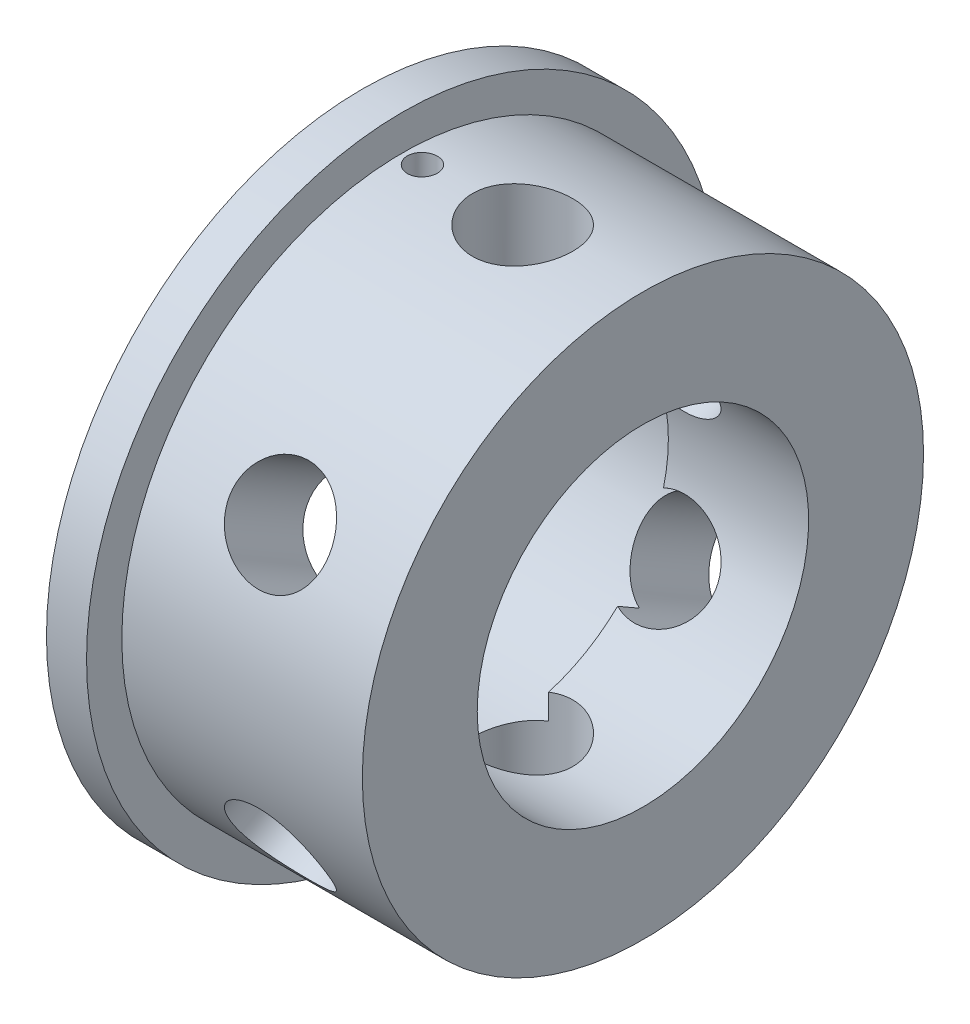
from build123d import *

# Parameters (mm, degrees)
SKETCH2_W               = 7.9375
SKETCH2_H               = 68.353179155
CIRPATTERN1_COUNT       = 6
SKETCH4_R               = 2.38125
CUT_EXTRUDE1_DEPTH      = 51.038
CUT_EXTRUDE1_DEPTH_BACK = 51.038


with BuildPart() as part:
    # Sketch1 → Revolve1 (revolve)
    with BuildSketch(Plane.XY):
        Polygon((-38.1, -44.45), (0, -44.45), (0, -26.2509), (-22.225, -26.2509), (-22.225, -30.099), (-44.45, -30.2895), (-44.45, -34.3535), (-44.45, -50.038), (-38.1, -50.038), align=None)
    revolve(axis=Axis((-44.45, 0, 0), (1, 0, 0)))

    # Sketch2 → 5/8 (0.625) Diameter Hole1 (revolve, cut)
    with BuildSketch(Plane(origin=(-19.05, 0, 0), x_dir=(0, 0, -1), z_dir=(1, 0, 0))):
        with Locations((3.96875, 34.176589578)):
            Rectangle(SKETCH2_W, SKETCH2_H)
    f_5_8_0_625_diameter_hole1 = revolve(axis=Axis((-19.05, -6.35, 0), (0, 1, 0)), mode=Mode.SUBTRACT)

    # CirPattern1: 5/8 (0.625) Diameter Hole1 ×6 about axis
    cirpattern1_axis = Axis((-44.45, 0, 0), (1, 0, 0))
    for i in range(1, CIRPATTERN1_COUNT):
        add(f_5_8_0_625_diameter_hole1.rotate(cirpattern1_axis, i * 360 / CIRPATTERN1_COUNT), mode=Mode.SUBTRACT)

    # Sketch4 → Cut-Extrude1 (cut, two sides)
    with BuildSketch(Plane(origin=(0, 0, 0), x_dir=(1, 0, 0), z_dir=(0, 1, 0))) as cut_extrude1_sk:
        with Locations((-34.925, 0)):
            Circle(SKETCH4_R)
    extrude(amount=CUT_EXTRUDE1_DEPTH, mode=Mode.SUBTRACT)
    extrude(cut_extrude1_sk.sketch, amount=-CUT_EXTRUDE1_DEPTH_BACK, mode=Mode.SUBTRACT)


solid = part.part
